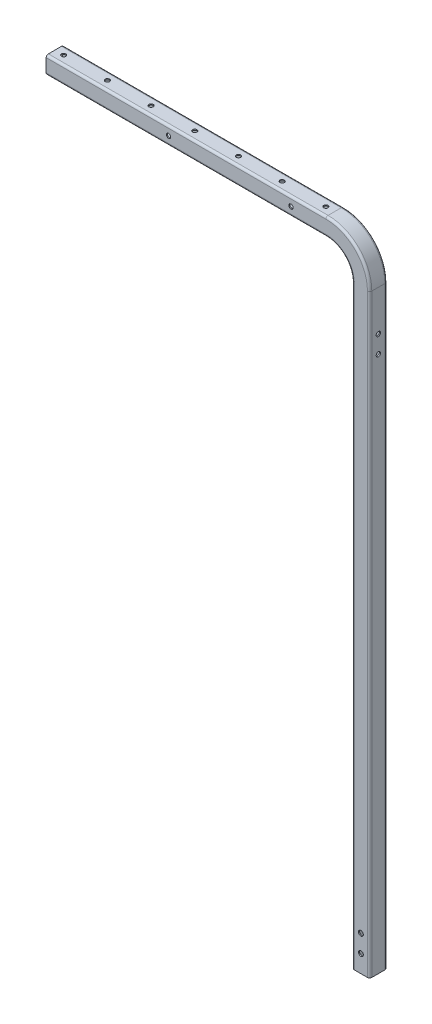
from build123d import *

# Parameters (mm, degrees)
SKETCH2_W                   = 25.4
SKETCH2_H                   = 25.4
FILLET1_R                   = 3.175
SHELL1_T                    = -1.5875
SKETCH3_R                   = 3.175
WOOD_HOLE_DEPTH             = 1.5875
LPATTERN1_COUNT             = 7
LPATTERN1_PITCH             = 63.5
SKETCH5_R                   = 3.175
CONT_MTG_DEPTH              = 470.9
F_1_4_0_25_DIAMETER_HOLE1_D = 6.35
SKETCH8_R                   = 3.571875
CUT_EXTRUDE1_DEPTH          = 26.4
LPATTERN2_COUNT             = 2
LPATTERN2_PITCH             = 25.4


with BuildPart() as part:
    # Base-Sweep: sweep along a path in Sketch1
    with BuildLine(Plane.XY) as base_sweep_path:
        Line((0, 0), (406.4, 0))
        ThreePointArc((406.4, 0), (442.321024484, -14.878975516), (457.2, -50.8))
        Line((457.2, -50.8), (457.2, -914.4))
    # Sketch2 (on Right Plane) → Base-Sweep (sweep)
    with BuildSketch(Plane(origin=(0, 0, 0), x_dir=(0, 0, -1), z_dir=(1, 0, 0))):
        Rectangle(SKETCH2_W, SKETCH2_H)
    sweep(path=base_sweep_path.line)

    # Fillet1
    fillet1_edges = [part.edges().sort_by_distance(p)[0] for p in [
        (451.301280605, -5.898719395, 12.7),
        (451.301280605, -5.898719395, -12.7),
        (433.340768363, -23.859231637, -12.7),
        (433.340768363, -23.859231637, 12.7),
        (469.9, -482.6, 12.7),
        (469.9, -482.6, -12.7),
        (444.5, -482.6, -12.7),
        (444.5, -482.6, 12.7),
        (203.2, 12.7, 12.7),
        (203.2, 12.7, -12.7),
        (203.2, -12.7, -12.7),
        (203.2, -12.7, 12.7),
    ]]
    fillet(fillet1_edges, radius=FILLET1_R)

    # Shell1
    shell1_openings = [part.faces().sort_by_distance(p)[0] for p in [
        (457.2, -914.4, 0),
        (0, 0, 0),
    ]]
    offset(amount=SHELL1_T, openings=shell1_openings, kind=Kind.INTERSECTION)

    # Sketch3 → Wood Hole (cut)
    with BuildSketch(Plane(origin=(0, 12.7, 0), x_dir=(-1, 0, 0), z_dir=(0, 1, 0))):
        with Locations((-12.7, 0)):
            Circle(SKETCH3_R)
    wood_hole = extrude(amount=-WOOD_HOLE_DEPTH, mode=Mode.SUBTRACT)

    # LPattern1: Wood Hole ×7
    with Locations(*[(i * LPATTERN1_PITCH, 0, 0) for i in range(1, LPATTERN1_COUNT)]):
        add(wood_hole, mode=Mode.SUBTRACT)

    # Sketch5 → cont_mtg (cut, through all)
    with BuildSketch(Plane(origin=(469.9, 0, 0), x_dir=(0, 0, -1), z_dir=(1, 0, 0))):
        with Locations((0, -109.5375)):
            Circle(SKETCH5_R)
        with Locations((0, -134.9375)):
            Circle(SKETCH5_R)
    extrude(amount=-CONT_MTG_DEPTH, mode=Mode.SUBTRACT)

    # 1/4 (0.25) Diameter Hole1 (through all)
    with Locations(Plane.XY.offset(12.7)):
        with Locations((177.8, 0), (355.6, 0)):
            Hole(F_1_4_0_25_DIAMETER_HOLE1_D / 2)

    # Sketch8 → Cut-Extrude1 (cut, through all)
    with BuildSketch(Plane(origin=(0, 0, -12.7), x_dir=(-1, 0, 0), z_dir=(0, 0, -1))):
        with Locations((-457.2, -889)):
            Circle(SKETCH8_R)
    cut_extrude1 = extrude(amount=-CUT_EXTRUDE1_DEPTH, mode=Mode.SUBTRACT)

    # LPattern2: Cut-Extrude1 ×2
    with Locations(*[(0, i * LPATTERN2_PITCH, 0) for i in range(1, LPATTERN2_COUNT)]):
        add(cut_extrude1, mode=Mode.SUBTRACT)


solid = part.part
